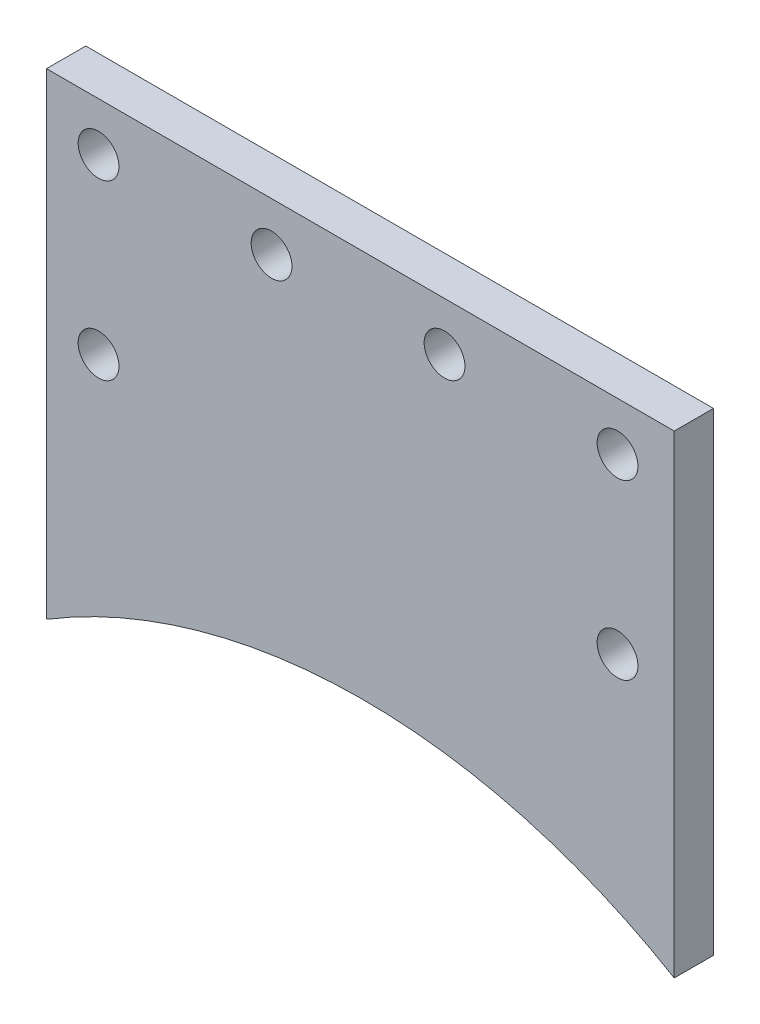
from build123d import *

# Parameters (mm, degrees)
SKETCH1_W           = 101.6
SKETCH1_H           = 77.11
BOSS_EXTRUDE1_DEPTH = 6.35
SKETCH2_R           = 98.5502
CUT_EXTRUDE1_DEPTH  = 7.35
SKETCH3_R           = 3.302
CUT_EXTRUDE2_DEPTH  = 7.35


with BuildPart() as part:
    # Sketch1 → Boss-Extrude1 (new body)
    with BuildSketch(Plane.XY):
        with Locations((1.062427377, -30.694895509)):
            Rectangle(SKETCH1_W, SKETCH1_H)
    extrude(amount=BOSS_EXTRUDE1_DEPTH)

    # Sketch2 → Cut-Extrude1 (cut, through all)
    with BuildSketch(Plane.XY.offset(6.35)):
        with Locations((1.501142757, -153.515944306)):
            Circle(SKETCH2_R)
    extrude(amount=-CUT_EXTRUDE1_DEPTH, mode=Mode.SUBTRACT)

    # Sketch3 → Cut-Extrude2 (cut, through all)
    with BuildSketch(Plane.XY.offset(6.35)):
        with Locations((-41.318062251, 0)):
            Circle(SKETCH3_R)
        with Locations((-13.318062251, 0)):
            Circle(SKETCH3_R)
        with Locations((14.681937749, 0)):
            Circle(SKETCH3_R)
        with Locations((42.681937749, 0)):
            Circle(SKETCH3_R)
        with Locations((-41.318062251, -28)):
            Circle(SKETCH3_R)
        with Locations((42.681937749, -28)):
            Circle(SKETCH3_R)
    extrude(amount=-CUT_EXTRUDE2_DEPTH, mode=Mode.SUBTRACT)


solid = part.part
